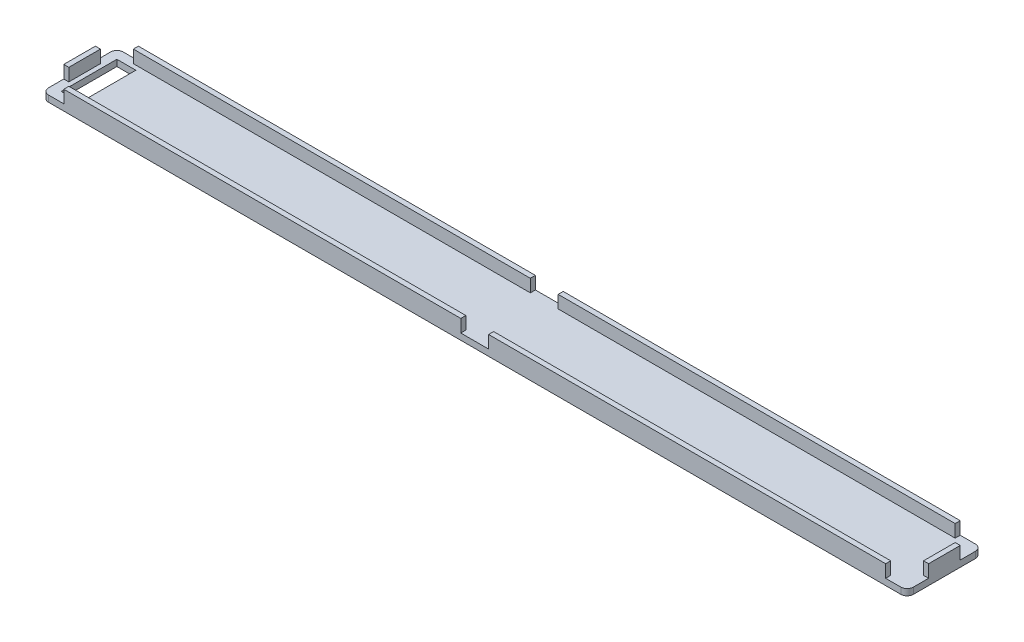
from build123d import *

# Parameters (mm, degrees)
ESQUISSE1_W             = 136.8
ESQUISSE1_H             = 11.8
BOSS_EXTRU_1_DEPTH      = 1
ESQUISSE4_W             = 136.8
ESQUISSE4_H             = 11.8
ESQUISSE4_W_2           = 135.2
ESQUISSE4_H_2           = 10.2
BOSS_EXTRU_3_DEPTH      = 2
ESQUISSE5_W             = 4.4
ESQUISSE5_H             = 0.8
ENL_V_MAT_EXTRU_3_DEPTH = 2
ESQUISSE6_W             = 3
ESQUISSE6_H             = 8.8
ENL_V_MAT_EXTRU_4_DEPTH = 4
CONG_1_R                = 1


with BuildPart() as part:
    # Esquisse1 → Boss.-Extru.1 (new body)
    with BuildSketch(Plane(origin=(0, 0, 0), x_dir=(1, 0, 0), z_dir=(0, 1, 0))):
        with Locations((68.4, 5.9)):
            Rectangle(ESQUISSE1_W, ESQUISSE1_H)
    extrude(amount=BOSS_EXTRU_1_DEPTH)

    # Esquisse4 → Boss.-Extru.3 (add)
    with BuildSketch(Plane(origin=(0, 1, 0), x_dir=(1, 0, 0), z_dir=(0, 1, 0))):
        with Locations((68.4, 5.9)):
            Rectangle(ESQUISSE4_W, ESQUISSE4_H)
        with Locations((68.4, 5.9)):
            Rectangle(ESQUISSE4_W_2, ESQUISSE4_H_2, mode=Mode.SUBTRACT)
    extrude(amount=BOSS_EXTRU_3_DEPTH)

    # Esquisse5 → Enlèv. mat.-Extru.3 (cut)
    with BuildSketch(Plane(origin=(0, 3, 0), x_dir=(1, 0, 0), z_dir=(0, 1, 0))):
        Polygon((136.8, 11.8), (136.8, 8.4), (136, 8.4), (136, 11), (133.4, 11), (133.4, 11.8), align=None)
        Polygon((3.4, 11.8), (0, 11.8), (0, 8.4), (0.8, 8.4), (0.8, 11), (3.4, 11), align=None)
        with Locations((68.4, 11.4)):
            Rectangle(ESQUISSE5_W, ESQUISSE5_H)
        Polygon((0, 0), (0, 3.4), (0.8, 3.4), (0.8, 0.8), (3.4, 0.8), (3.4, 0), align=None)
        with Locations((68.4, 0.4)):
            Rectangle(ESQUISSE5_W, ESQUISSE5_H)
        Polygon((133.4, 0), (136.8, 0), (136.8, 3.4), (136, 3.4), (136, 0.8), (133.4, 0.8), align=None)
    extrude(amount=-ENL_V_MAT_EXTRU_3_DEPTH, mode=Mode.SUBTRACT)

    # Esquisse6 → Enlèv. mat.-Extru.4 (cut, through all)
    with BuildSketch(Plane.XZ):
        with Locations((3, -5.9)):
            Rectangle(ESQUISSE6_W, ESQUISSE6_H)
    extrude(amount=-ENL_V_MAT_EXTRU_4_DEPTH, mode=Mode.SUBTRACT)

    # Congé1
    cong_1_edges = [part.edges().sort_by_distance(p)[0] for p in [
        (0, 0.5, -11.8),
        (136.8, 0.5, -11.8),
        (136.8, 0.5, 0),
        (0, 0.5, 0),
    ]]
    fillet(cong_1_edges, radius=CONG_1_R)


solid = part.part
